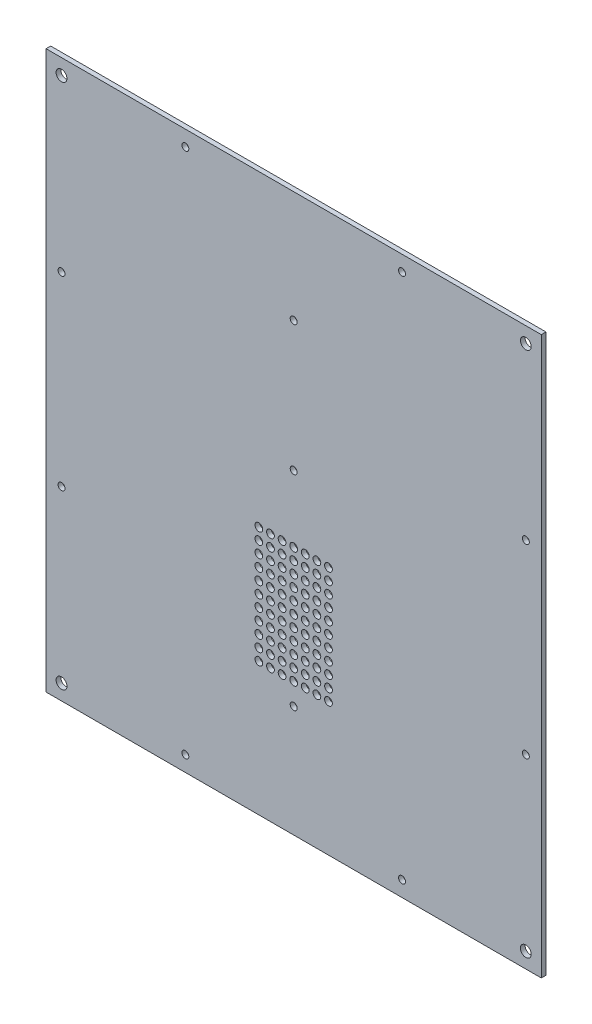
from build123d import *

# Parameters (mm, degrees)
SKETCH_1_W          = 320
SKETCH_1_H          = 360
SKETCH_1_R          = 2.25
EXTRUDE_1_DEPTH     = 3
SKETCH_2_R          = 3.5
CUT_EXTRUDE_1_DEPTH = 4
SKETCH_4_R          = 2.25
SKETCH_4_R_2        = 2.5
CUT_EXTRUDE_2_DEPTH = 4


with BuildPart() as part:
    # Эскиз1 → Бобышка-Вытянуть1 (new body)
    with BuildSketch(Plane.XY):
        with Locations((160, 180)):
            Rectangle(SKETCH_1_W, SKETCH_1_H)
        with Locations((90, 10)):
            Circle(SKETCH_1_R, mode=Mode.SUBTRACT)
        with Locations((90, 350)):
            Circle(SKETCH_1_R, mode=Mode.SUBTRACT)
        with Locations((230, 350)):
            Circle(SKETCH_1_R, mode=Mode.SUBTRACT)
        with Locations((230, 10)):
            Circle(SKETCH_1_R, mode=Mode.SUBTRACT)
        with Locations((10, 240)):
            Circle(SKETCH_1_R, mode=Mode.SUBTRACT)
        with Locations((10, 120)):
            Circle(SKETCH_1_R, mode=Mode.SUBTRACT)
        with Locations((310, 240)):
            Circle(SKETCH_1_R, mode=Mode.SUBTRACT)
        with Locations((310, 120)):
            Circle(SKETCH_1_R, mode=Mode.SUBTRACT)
    extrude(amount=EXTRUDE_1_DEPTH)

    # Эскиз2 → Вырез-Вытянуть1 (cut, through all)
    with BuildSketch(Plane.XY.offset(3)):
        with Locations((10, 350)):
            Circle(SKETCH_2_R)
        with Locations((310, 350)):
            Circle(SKETCH_2_R)
        with Locations((310, 10)):
            Circle(SKETCH_2_R)
        with Locations((10, 10)):
            Circle(SKETCH_2_R)
    extrude(amount=-CUT_EXTRUDE_1_DEPTH, mode=Mode.SUBTRACT)

    # Эскиз4 → Вырез-Вытянуть2 (cut, through all)
    with BuildSketch(Plane.XY.offset(3)):
        with Locations((160, 288)):
            Circle(SKETCH_4_R)
        with Locations((160, 204)):
            Circle(SKETCH_4_R)
        with Locations((160, 72)):
            Circle(SKETCH_4_R)
        with Locations((137.5, 86)):
            Circle(SKETCH_4_R_2)
        with Locations((145, 86)):
            Circle(SKETCH_4_R_2)
        with Locations((152.5, 86)):
            Circle(SKETCH_4_R_2)
        with Locations((160, 86)):
            Circle(SKETCH_4_R_2)
        with Locations((167.5, 86)):
            Circle(SKETCH_4_R_2)
        with Locations((175, 86)):
            Circle(SKETCH_4_R_2)
        with Locations((182.5, 86)):
            Circle(SKETCH_4_R_2)
        with Locations((137.5, 93.5)):
            Circle(SKETCH_4_R_2)
        with Locations((145, 93.5)):
            Circle(SKETCH_4_R_2)
        with Locations((152.5, 93.5)):
            Circle(SKETCH_4_R_2)
        with Locations((160, 93.5)):
            Circle(SKETCH_4_R_2)
        with Locations((167.5, 93.5)):
            Circle(SKETCH_4_R_2)
        with Locations((175, 93.5)):
            Circle(SKETCH_4_R_2)
        with Locations((182.5, 93.5)):
            Circle(SKETCH_4_R_2)
        with Locations((137.5, 101)):
            Circle(SKETCH_4_R_2)
        with Locations((145, 101)):
            Circle(SKETCH_4_R_2)
        with Locations((152.5, 101)):
            Circle(SKETCH_4_R_2)
        with Locations((160, 101)):
            Circle(SKETCH_4_R_2)
        with Locations((167.5, 101)):
            Circle(SKETCH_4_R_2)
        with Locations((175, 101)):
            Circle(SKETCH_4_R_2)
        with Locations((182.5, 101)):
            Circle(SKETCH_4_R_2)
        with Locations((137.5, 108.5)):
            Circle(SKETCH_4_R_2)
        with Locations((145, 108.5)):
            Circle(SKETCH_4_R_2)
        with Locations((152.5, 108.5)):
            Circle(SKETCH_4_R_2)
        with Locations((160, 108.5)):
            Circle(SKETCH_4_R_2)
        with Locations((167.5, 108.5)):
            Circle(SKETCH_4_R_2)
        with Locations((175, 108.5)):
            Circle(SKETCH_4_R_2)
        with Locations((182.5, 108.5)):
            Circle(SKETCH_4_R_2)
        with Locations((137.5, 116)):
            Circle(SKETCH_4_R_2)
        with Locations((145, 116)):
            Circle(SKETCH_4_R_2)
        with Locations((152.5, 116)):
            Circle(SKETCH_4_R_2)
        with Locations((160, 116)):
            Circle(SKETCH_4_R_2)
        with Locations((167.5, 116)):
            Circle(SKETCH_4_R_2)
        with Locations((175, 116)):
            Circle(SKETCH_4_R_2)
        with Locations((182.5, 116)):
            Circle(SKETCH_4_R_2)
        with Locations((137.5, 123.5)):
            Circle(SKETCH_4_R_2)
        with Locations((145, 123.5)):
            Circle(SKETCH_4_R_2)
        with Locations((152.5, 123.5)):
            Circle(SKETCH_4_R_2)
        with Locations((160, 123.5)):
            Circle(SKETCH_4_R_2)
        with Locations((167.5, 123.5)):
            Circle(SKETCH_4_R_2)
        with Locations((175, 123.5)):
            Circle(SKETCH_4_R_2)
        with Locations((182.5, 123.5)):
            Circle(SKETCH_4_R_2)
        with Locations((137.5, 131)):
            Circle(SKETCH_4_R_2)
        with Locations((145, 131)):
            Circle(SKETCH_4_R_2)
        with Locations((152.5, 131)):
            Circle(SKETCH_4_R_2)
        with Locations((160, 131)):
            Circle(SKETCH_4_R_2)
        with Locations((167.5, 131)):
            Circle(SKETCH_4_R_2)
        with Locations((175, 131)):
            Circle(SKETCH_4_R_2)
        with Locations((182.5, 131)):
            Circle(SKETCH_4_R_2)
        with Locations((137.5, 138.5)):
            Circle(SKETCH_4_R_2)
        with Locations((145, 138.5)):
            Circle(SKETCH_4_R_2)
        with Locations((152.5, 138.5)):
            Circle(SKETCH_4_R_2)
        with Locations((160, 138.5)):
            Circle(SKETCH_4_R_2)
        with Locations((167.5, 138.5)):
            Circle(SKETCH_4_R_2)
        with Locations((175, 138.5)):
            Circle(SKETCH_4_R_2)
        with Locations((182.5, 138.5)):
            Circle(SKETCH_4_R_2)
        with Locations((137.5, 146)):
            Circle(SKETCH_4_R_2)
        with Locations((145, 146)):
            Circle(SKETCH_4_R_2)
        with Locations((152.5, 146)):
            Circle(SKETCH_4_R_2)
        with Locations((160, 146)):
            Circle(SKETCH_4_R_2)
        with Locations((167.5, 146)):
            Circle(SKETCH_4_R_2)
        with Locations((175, 146)):
            Circle(SKETCH_4_R_2)
        with Locations((182.5, 146)):
            Circle(SKETCH_4_R_2)
        with Locations((137.5, 153.5)):
            Circle(SKETCH_4_R_2)
        with Locations((145, 153.5)):
            Circle(SKETCH_4_R_2)
        with Locations((152.5, 153.5)):
            Circle(SKETCH_4_R_2)
        with Locations((160, 153.5)):
            Circle(SKETCH_4_R_2)
        with Locations((167.5, 153.5)):
            Circle(SKETCH_4_R_2)
        with Locations((175, 153.5)):
            Circle(SKETCH_4_R_2)
        with Locations((182.5, 153.5)):
            Circle(SKETCH_4_R_2)
        with Locations((137.5, 161)):
            Circle(SKETCH_4_R_2)
        with Locations((145, 161)):
            Circle(SKETCH_4_R_2)
        with Locations((152.5, 161)):
            Circle(SKETCH_4_R_2)
        with Locations((160, 161)):
            Circle(SKETCH_4_R_2)
        with Locations((167.5, 161)):
            Circle(SKETCH_4_R_2)
        with Locations((175, 161)):
            Circle(SKETCH_4_R_2)
        with Locations((182.5, 161)):
            Circle(SKETCH_4_R_2)
    extrude(amount=-CUT_EXTRUDE_2_DEPTH, mode=Mode.SUBTRACT)


solid = part.part
